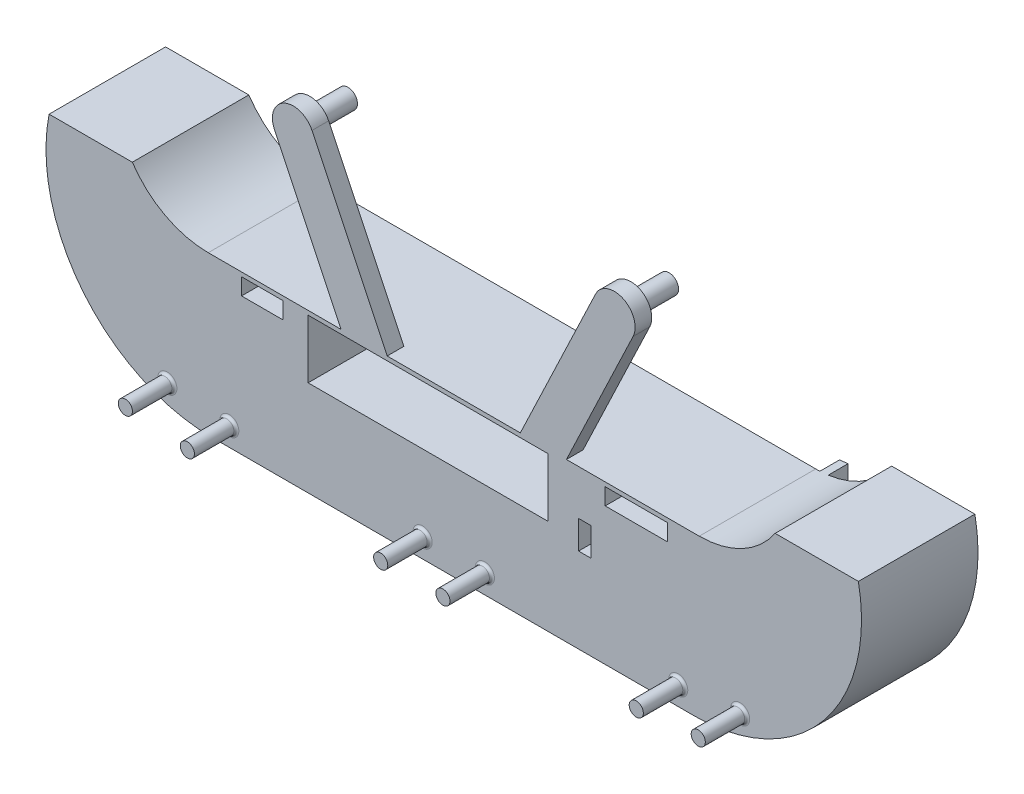
from build123d import *

# Parameters (mm, degrees)
BOSS_EXTRUDE1_DEPTH     = 6.35
SKETCH2_R               = 1.4605
BOSS_EXTRUDE2_DEPTH     = 2
SKETCH3_W               = 29.464
SKETCH3_H               = 5.08
SKETCH3_W_2             = 6.35
SKETCH3_H_2             = 2.54
SKETCH3_W_3             = 9.525
SKETCH3_W_4             = 1.905
SKETCH3_H_3             = 4.318
CUT_EXTRUDE1_DEPTH      = 3.81
BOSS_EXTRUDE3_DEPTH     = 1.5748
BOSS_EXTRUDE4_DEPTH     = 2.54
SKETCH6_R               = 1.0795
BOSS_EXTRUDE5_DEPTH     = 6.4
SKETCH7_R               = 1.0922
SKETCH7_W               = 29.464
SKETCH7_H               = 5.08
SKETCH7_W_2             = 9.525
SKETCH7_H_2             = 2.54
SKETCH7_W_3             = 1.905
SKETCH7_H_3             = 4.318
SKETCH7_W_4             = 6.35
BOSS_EXTRUDE6_DEPTH     = 15.24
SKETCH8_R               = 1.4605
BOSS_EXTRUDE7_DEPTH     = 3.81
BOSS_EXTRUDE8_START     = -13.6652
SKETCH9_R               = 1.0668
BOSS_EXTRUDE8_DEPTH     = 15.4432
BOSS_EXTRUDE9_DEPTH     = 3.0248
FILLET1_R               = 0.381
SKETCH12_W              = 29.464
SKETCH12_H              = 5.08
CUT_EXTRUDE2_DEPTH      = 3.59
CUT_EXTRUDE2_DEPTH_BACK = 25.6148
SKETCH13_W              = 36.576
SKETCH13_H              = 8.9408
CUT_EXTRUDE3_DEPTH      = 3.59
CUT_EXTRUDE3_DEPTH_BACK = 25.6148
SKETCH14_W              = 36.576
SKETCH14_H              = 8.9408
CUT_EXTRUDE4_DEPTH      = 3.59
CUT_EXTRUDE4_DEPTH_BACK = 3.81


with BuildPart() as part:
    # Sketch1 → Boss-Extrude1 (new body)
    with BuildSketch(Plane.XY):
        with BuildLine():
            Line((26.244357922, -195.106843749), (37.718201994, -219.182553546))
            Line((37.718201994, -219.182553546), (58.038201994, -219.182553546))
            Line((58.038201994, -219.182553546), (69.512046065, -195.106843749))
            ThreePointArc((69.512046065, -195.106843749), (73.744135812, -193.606621639), (75.244357922, -197.838711386))
            Line((75.244357922, -197.838711386), (65.072449433, -219.182553546))
            Line((65.072449433, -219.182553546), (85.343201994, -219.182553546))
            Line((85.343201994, -219.182553546), (85.343201994, -233.152553546))
            Line((85.343201994, -233.152553546), (10.413201994, -233.152553546))
            Line((10.413201994, -233.152553546), (10.413201994, -219.182553546))
            Line((10.413201994, -219.182553546), (30.683954554, -219.182553546))
            Line((30.683954554, -219.182553546), (20.512046065, -197.838711386))
            ThreePointArc((20.512046065, -197.838711386), (22.012268176, -193.606621639), (26.244357922, -195.106843749))
        make_face()
    extrude(amount=BOSS_EXTRUDE1_DEPTH)

    # Sketch2 → Boss-Extrude2 (add)
    with BuildSketch(Plane(origin=(0, 0, 0), x_dir=(-1, 0, 0), z_dir=(0, 0, -1))):
        with Locations((-23.378201994, -196.472777568)):
            Circle(SKETCH2_R)
        with Locations((-72.378201994, -196.472777568)):
            Circle(SKETCH2_R)
    extrude(amount=BOSS_EXTRUDE2_DEPTH)

    # Sketch3 → Cut-Extrude1 (cut)
    with BuildSketch(Plane(origin=(0, 0, 0), x_dir=(-1, 0, 0), z_dir=(0, 0, -1))):
        with Locations((-44.957201994, -222.357553546)):
            Rectangle(SKETCH3_W, SKETCH3_H)
        with Locations((-18.668201994, -221.087553546)):
            Rectangle(SKETCH3_W_2, SKETCH3_H_2)
        with Locations((-75.754701994, -221.087553546)):
            Rectangle(SKETCH3_W_3, SKETCH3_H_2)
        with Locations((-67.880701994, -228.199553546)):
            Rectangle(SKETCH3_W_4, SKETCH3_H_3)
    extrude(amount=-CUT_EXTRUDE1_DEPTH, mode=Mode.SUBTRACT)

    # Sketch4 → Boss-Extrude3 (add)
    with BuildSketch(Plane(origin=(0, 0, 0), x_dir=(-1, 0, 0), z_dir=(0, 0, -1))):
        with BuildLine():
            ThreePointArc((-11.861001994, -222.357553546), (-12.953201994, -221.265353546), (-14.045401994, -222.357553546))
            ThreePointArc((-14.045401994, -222.357553546), (-12.953201994, -223.449753546), (-11.861001994, -222.357553546))
        make_face()
        with BuildLine():
            ThreePointArc((-62.661001994, -222.357553546), (-63.753201994, -221.265353546), (-64.845401994, -222.357553546))
            ThreePointArc((-64.845401994, -222.357553546), (-63.753201994, -223.449753546), (-62.661001994, -222.357553546))
        make_face()
        with BuildLine():
            ThreePointArc((-67.741001994, -222.357553546), (-68.833201994, -221.265353546), (-69.925401994, -222.357553546))
            ThreePointArc((-69.925401994, -222.357553546), (-68.833201994, -223.449753546), (-67.741001994, -222.357553546))
        make_face()
        with BuildLine():
            ThreePointArc((-81.711001994, -222.357553546), (-82.803201994, -221.265353546), (-83.895401994, -222.357553546))
            ThreePointArc((-83.895401994, -222.357553546), (-82.803201994, -223.449753546), (-81.711001994, -222.357553546))
        make_face()
    extrude(amount=BOSS_EXTRUDE3_DEPTH)

    # Sketch5 → Boss-Extrude4 (add)
    with BuildSketch(Plane(origin=(0, 0, 0), x_dir=(-1, 0, 0), z_dir=(0, 0, -1))):
        with BuildLine():
            Line((13.875087762, -213.01463279), (1.175087762, -213.01463279))
            ThreePointArc((1.175087762, -213.01463279), (-3.84944343, -217.54454339), (-10.413201994, -219.182553546))
            Line((-10.413201994, -219.182553546), (-10.413201994, -233.152553546))
            Line((-10.413201994, -233.152553546), (-85.343201994, -233.152553546))
            Line((-85.343201994, -233.152553546), (-85.343201994, -219.182553546))
            ThreePointArc((-85.343201994, -219.182553546), (-91.906960557, -217.54454339), (-96.93149175, -213.01463279))
            Line((-96.93149175, -213.01463279), (-109.63149175, -213.01463279))
            ThreePointArc((-109.63149175, -213.01463279), (-104.324103543, -234.048736688), (-84.708201994, -243.312553546))
            Line((-84.708201994, -243.312553546), (-11.048201994, -243.312553546))
            ThreePointArc((-11.048201994, -243.312553546), (8.567699556, -234.048736688), (13.875087762, -213.01463279))
        make_face()
    extrude(amount=-BOSS_EXTRUDE4_DEPTH)

    # Sketch6 → Boss-Extrude5 (add)
    with BuildSketch(Plane.XY.offset(2.54)):
        with Locations((52.628201994, -240.391553546)):
            Circle(SKETCH6_R)
        with Locations((43.128201994, -240.391553546)):
            Circle(SKETCH6_R)
        with Locations((4.166376212, -239.533120091)):
            Circle(SKETCH6_R)
        with Locations((13.623539791, -240.434262169)):
            Circle(SKETCH6_R)
        with Locations((82.132864197, -240.434262169)):
            Circle(SKETCH6_R)
        with Locations((91.590027775, -239.533120091)):
            Circle(SKETCH6_R)
    extrude(amount=BOSS_EXTRUDE5_DEPTH)

    # Sketch7 → Boss-Extrude6 (add)
    with BuildSketch(Plane(origin=(0, 0, 0), x_dir=(-1, 0, 0), z_dir=(0, 0, -1))):
        with BuildLine():
            Line((-30.683954554, -219.182553546), (-37.718201994, -219.182553546))
            Line((-37.718201994, -219.182553546), (-58.038201994, -219.182553546))
            Line((-58.038201994, -219.182553546), (-65.072449433, -219.182553546))
            Line((-65.072449433, -219.182553546), (-85.343201994, -219.182553546))
            ThreePointArc((-85.343201994, -219.182553546), (-91.906960557, -217.54454339), (-96.93149175, -213.01463279))
            Line((-96.93149175, -213.01463279), (-109.63149175, -213.01463279))
            ThreePointArc((-109.63149175, -213.01463279), (-104.324103543, -234.048736688), (-84.708201994, -243.312553546))
            Line((-84.708201994, -243.312553546), (-11.048201994, -243.312553546))
            ThreePointArc((-11.048201994, -243.312553546), (8.567699556, -234.048736688), (13.875087762, -213.01463279))
            Line((13.875087762, -213.01463279), (1.175087762, -213.01463279))
            ThreePointArc((1.175087762, -213.01463279), (-3.84944343, -217.54454339), (-10.413201994, -219.182553546))
            Line((-10.413201994, -219.182553546), (-30.683954554, -219.182553546))
        make_face()
        with Locations((-82.803201994, -222.357553546)):
            Circle(SKETCH7_R, mode=Mode.SUBTRACT)
        with Locations((-12.953201994, -222.357553546)):
            Circle(SKETCH7_R, mode=Mode.SUBTRACT)
        with Locations((-68.833201994, -222.357553546)):
            Circle(SKETCH7_R, mode=Mode.SUBTRACT)
        with Locations((-63.753201994, -222.357553546)):
            Circle(SKETCH7_R, mode=Mode.SUBTRACT)
        with Locations((-44.957201994, -222.357553546)):
            Rectangle(SKETCH7_W, SKETCH7_H, mode=Mode.SUBTRACT)
        with Locations((-75.754701994, -221.087553546)):
            Rectangle(SKETCH7_W_2, SKETCH7_H_2, mode=Mode.SUBTRACT)
        with Locations((-67.880701994, -228.199553546)):
            Rectangle(SKETCH7_W_3, SKETCH7_H_3, mode=Mode.SUBTRACT)
        with Locations((-18.668201994, -221.087553546)):
            Rectangle(SKETCH7_W_4, SKETCH7_H_2, mode=Mode.SUBTRACT)
    extrude(amount=BOSS_EXTRUDE6_DEPTH)

    # Sketch8 → Boss-Extrude7 (add)
    with BuildSketch(Plane(origin=(0, 0, -2), x_dir=(-1, 0, 0), z_dir=(0, 0, -1))):
        with Locations((-72.378201994, -196.472777568)):
            Circle(SKETCH8_R)
        with Locations((-23.378201994, -196.472777568)):
            Circle(SKETCH8_R)
    extrude(amount=BOSS_EXTRUDE7_DEPTH)

    # Sketch9 → Boss-Extrude8 (add)
    with BuildSketch(Plane(origin=(0, 0, -15.24), x_dir=(-1, 0, 0), z_dir=(0, 0, -1)).offset(BOSS_EXTRUDE8_START)):
        with Locations((-82.803201994, -222.357553546)):
            Circle(SKETCH9_R)
        with Locations((-63.753201994, -222.357553546)):
            Circle(SKETCH9_R)
        with Locations((-68.833201994, -222.357553546)):
            Circle(SKETCH9_R)
        with Locations((-12.953201994, -222.357553546)):
            Circle(SKETCH9_R)
    extrude(amount=BOSS_EXTRUDE8_DEPTH)

    # Sketch10 → Boss-Extrude9 (add)
    with BuildSketch(Plane(origin=(0, 0, -15.24), x_dir=(-1, 0, 0), z_dir=(0, 0, -1))):
        with BuildLine():
            Line((-87.248201994, -235.816057692), (-8.508201994, -235.816057692))
            Line((-8.508201994, -235.816057692), (-8.508201994, -219.052057692))
            ThreePointArc((-8.508201994, -219.052057692), (-9.141876983, -219.124585487), (-9.778201994, -219.168114266))
            Line((-9.778201994, -219.168114266), (-9.778201994, -233.276057692))
            Line((-9.778201994, -233.276057692), (-85.978201994, -233.276057692))
            Line((-85.978201994, -233.276057692), (-85.978201994, -219.168114266))
            ThreePointArc((-85.978201994, -219.168114266), (-86.614527004, -219.124585487), (-87.248201994, -219.052057692))
            Line((-87.248201994, -219.052057692), (-87.248201994, -235.816057692))
        make_face()
    extrude(amount=BOSS_EXTRUDE9_DEPTH)

    # Fillet1
    fillet1_edges = [part.edges().sort_by_distance(p)[0] for p in [
        (51.548701994, -240.391553546, 2.54),
        (42.048701994, -240.391553546, 2.54),
        (12.544039791, -240.434262169, 2.54),
        (3.086876212, -239.533120091, 2.54),
        (81.053364197, -240.434262169, 2.54),
        (90.510527775, -239.533120091, 2.54),
    ]]
    fillet(fillet1_edges, radius=FILLET1_R)

    # Sketch12 → Cut-Extrude2 (cut, two sides)
    with BuildSketch(Plane.XY.offset(6.35)) as cut_extrude2_sk:
        with Locations((44.957201994, -222.357553546)):
            Rectangle(SKETCH12_W, SKETCH12_H)
    extrude(amount=CUT_EXTRUDE2_DEPTH, mode=Mode.SUBTRACT)
    extrude(cut_extrude2_sk.sketch, amount=-CUT_EXTRUDE2_DEPTH_BACK, mode=Mode.SUBTRACT)

    # Sketch13 → Cut-Extrude3 (cut, two sides)
    with BuildSketch(Plane.XY.offset(6.35)) as cut_extrude3_sk:
        with Locations((43.941201994, -224.287953546)):
            Rectangle(SKETCH13_W, SKETCH13_H)
    extrude(amount=CUT_EXTRUDE3_DEPTH, mode=Mode.SUBTRACT)
    extrude(cut_extrude3_sk.sketch, amount=-CUT_EXTRUDE3_DEPTH_BACK, mode=Mode.SUBTRACT)

    # Sketch14 → Cut-Extrude4 (cut, two sides)
    with BuildSketch(Plane.XY.offset(6.35)) as cut_extrude4_sk:
        with BuildLine():
            Line((85.343201994, -219.182553546), (65.072449433, -219.182553546))
            Line((65.072449433, -219.182553546), (75.244357922, -197.838711386))
            ThreePointArc((75.244357922, -197.838711386), (73.744135812, -193.606621639), (69.512046065, -195.106843749))
            Line((69.512046065, -195.106843749), (58.038201994, -219.182553546))
            Line((58.038201994, -219.182553546), (37.718201994, -219.182553546))
            Line((37.718201994, -219.182553546), (26.244357922, -195.106843749))
            ThreePointArc((26.244357922, -195.106843749), (22.012268176, -193.606621639), (20.512046065, -197.838711386))
            Line((20.512046065, -197.838711386), (30.683954554, -219.182553546))
            Line((30.683954554, -219.182553546), (10.413201994, -219.182553546))
            Line((10.413201994, -219.182553546), (10.413201994, -233.152553546))
            Line((10.413201994, -233.152553546), (85.343201994, -233.152553546))
            Line((85.343201994, -233.152553546), (85.343201994, -219.182553546))
        make_face()
        with Locations((43.941201994, -224.287953546)):
            Rectangle(SKETCH14_W, SKETCH14_H, mode=Mode.SUBTRACT)
    extrude(amount=CUT_EXTRUDE4_DEPTH, mode=Mode.SUBTRACT)
    extrude(cut_extrude4_sk.sketch, amount=-CUT_EXTRUDE4_DEPTH_BACK, mode=Mode.SUBTRACT)


solid = part.part
